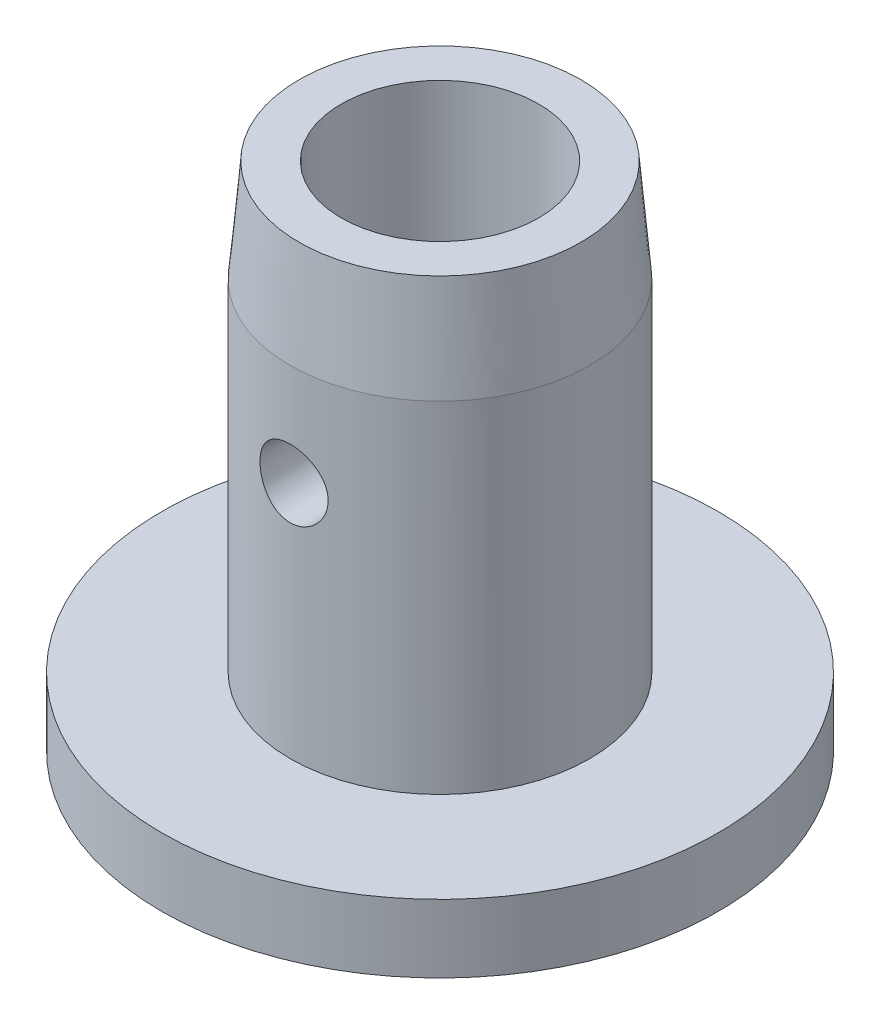
from build123d import *

# Parameters (mm, degrees)
IZIM1_R                     = 8.171332893
IZIM1_R_2                   = 4.4
Y_KSEKLIK_EKSTR_ZYON1_DEPTH = 2
IZIM1_3_R                   = 4.4
IZIM1_3_R_2                 = 2.9
EKSTR_ZYON_NCE1_DEPTH       = 15
PAH1_SIZE                   = 3
PAH1_SIZE2                  = 0.262465991
IZIM2_R                     = 1
KES_EKSTR_ZYON1_DEPTH       = 19.935188473
KES_EKSTR_ZYON1_DEPTH_BACK  = 19.935188473


with BuildPart() as part:
    # izim1 → Y_kseklik-Ekstr_zyon1 (new body)
    with BuildSketch(Plane(origin=(0, 0, 0), x_dir=(1, 0, 0), z_dir=(0, 1, 0))):
        with Locations(Location((0, 0, 0), (0, 0, 270))):
            Circle(IZIM1_R)
        Circle(IZIM1_R_2, mode=Mode.SUBTRACT)
        Circle(IZIM1_R_2)
    extrude(amount=Y_KSEKLIK_EKSTR_ZYON1_DEPTH)

    # izim1_3 → Ekstr_zyon-_nce1 (add)
    with BuildSketch(Plane(origin=(0, 0, 0), x_dir=(1, 0, 0), z_dir=(0, 1, 0))):
        Circle(IZIM1_3_R)
        Circle(IZIM1_3_R_2, mode=Mode.SUBTRACT)
    extrude(amount=EKSTR_ZYON_NCE1_DEPTH)

    # Pah1
    pah1_edges = [part.edges().sort_by_distance(p)[0] for p in [
        (-4.4, 15, 0),
    ]]
    pah1_side = [part.faces().sort_by_distance(p)[0] for p in [
        (-4.4, 8.5, 0),
    ]]
    chamfer(pah1_edges, length=PAH1_SIZE, length2=PAH1_SIZE2, reference=pah1_side[0])

    # izim2 → Kes-Ekstr_zyon1 (cut, two sides)
    with BuildSketch(Plane.XY) as kes_ekstr_zyon1_sk:
        with Locations((0, 9)):
            Circle(IZIM2_R)
    extrude(amount=KES_EKSTR_ZYON1_DEPTH, mode=Mode.SUBTRACT)
    extrude(kes_ekstr_zyon1_sk.sketch, amount=-KES_EKSTR_ZYON1_DEPTH_BACK, mode=Mode.SUBTRACT)


solid = part.part
